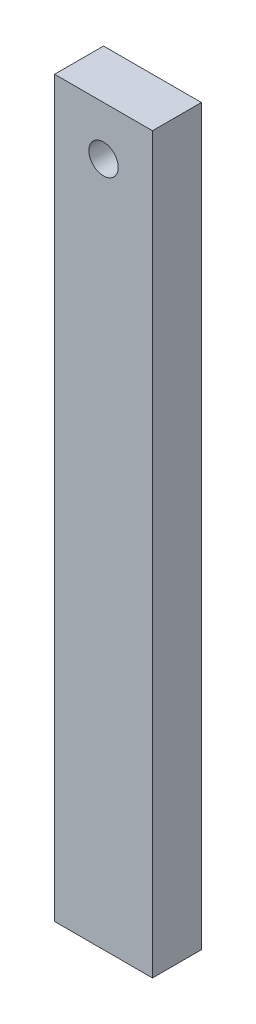
from build123d import *

# Parameters (mm, degrees)
SKETCH2_W           = 20
SKETCH2_H           = 150
BOSS_EXTRUDE1_DEPTH = 10
SKETCH3_R           = 3
CUT_EXTRUDE1_DEPTH  = 10


with BuildPart() as part:
    # Sketch2 → Boss-Extrude1 (new body)
    with BuildSketch(Plane.XY):
        Rectangle(SKETCH2_W, SKETCH2_H)
    extrude(amount=BOSS_EXTRUDE1_DEPTH)

    # Sketch3 → Cut-Extrude1 (cut)
    with BuildSketch(Plane.XY.offset(10)):
        with Locations((0, 65)):
            Circle(SKETCH3_R)
    extrude(amount=-CUT_EXTRUDE1_DEPTH, mode=Mode.SUBTRACT)


solid = part.part
